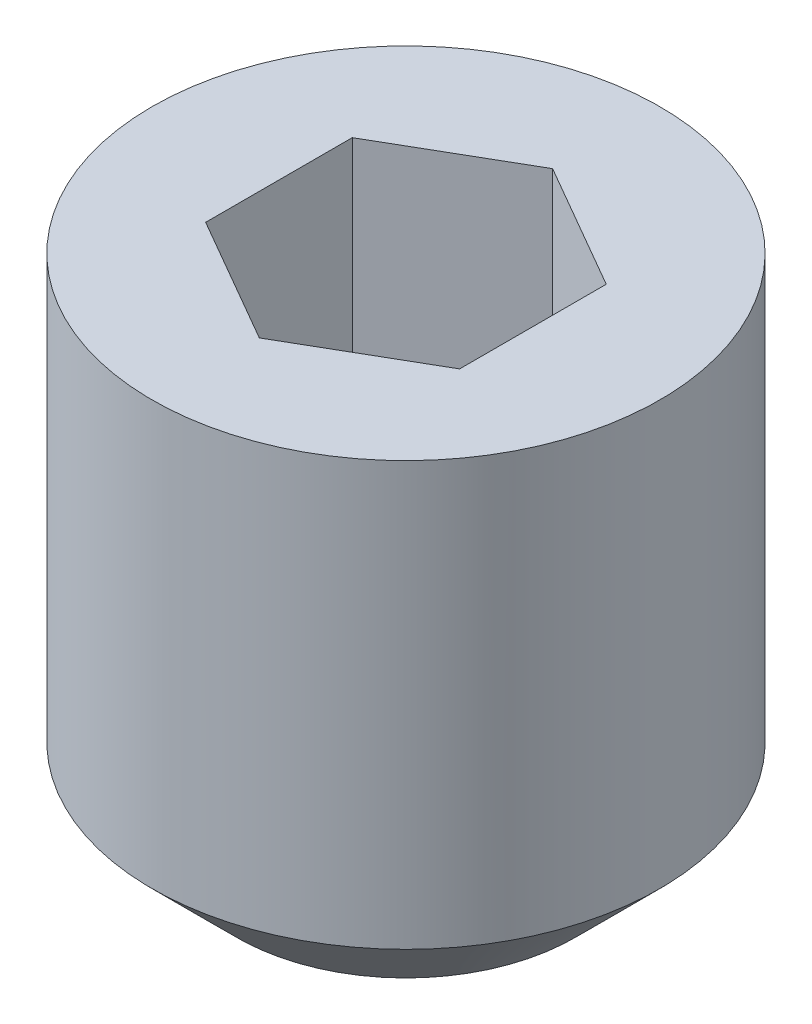
from build123d import *

# Parameters (mm, degrees)
SKETCH1_W          = 1.5
SKETCH1_H          = 3
CUT_EXTRUDE1_DEPTH = 1.2


with BuildPart() as part:
    # Sketch1 → Revolve1 (revolve)
    with BuildSketch(Plane.XY):
        with Locations((0.75, 1.5)):
            Rectangle(SKETCH1_W, SKETCH1_H)
    revolve(axis=Axis((0, 3, 0), (0, -1, 0)))

    # Sketch2 → Cut-Revolve1 (revolve, cut)
    with BuildSketch(Plane.XY):
        Polygon((0, 3), (0.75, 3), (0.75, 1.8), (0, 1.366987298), align=None)
    revolve(axis=Axis((0, 3, 0), (0, -1, 0)), mode=Mode.SUBTRACT)

    # Sketch3 → Cut-Extrude1 (cut)
    with BuildSketch(Plane(origin=(0, 3, 0), x_dir=(1, 0, 0), z_dir=(0, 1, 0))):
        Polygon((0, 0.866025404), (-0.75, 0.433012702), (-0.75, -0.433012702), (0, -0.866025404), (0.75, -0.433012702), (0.75, 0.433012702), align=None)
    extrude(amount=-CUT_EXTRUDE1_DEPTH, mode=Mode.SUBTRACT)

    # Sketch4 → Cut-Revolve2 (revolve, cut)
    with BuildSketch(Plane.XY):
        Polygon((1, 0), (1.5, 0), (1.5, 0.5), align=None)
    revolve(axis=Axis((0, 0, 0), (0, 1, 0)), mode=Mode.SUBTRACT)


solid = part.part
